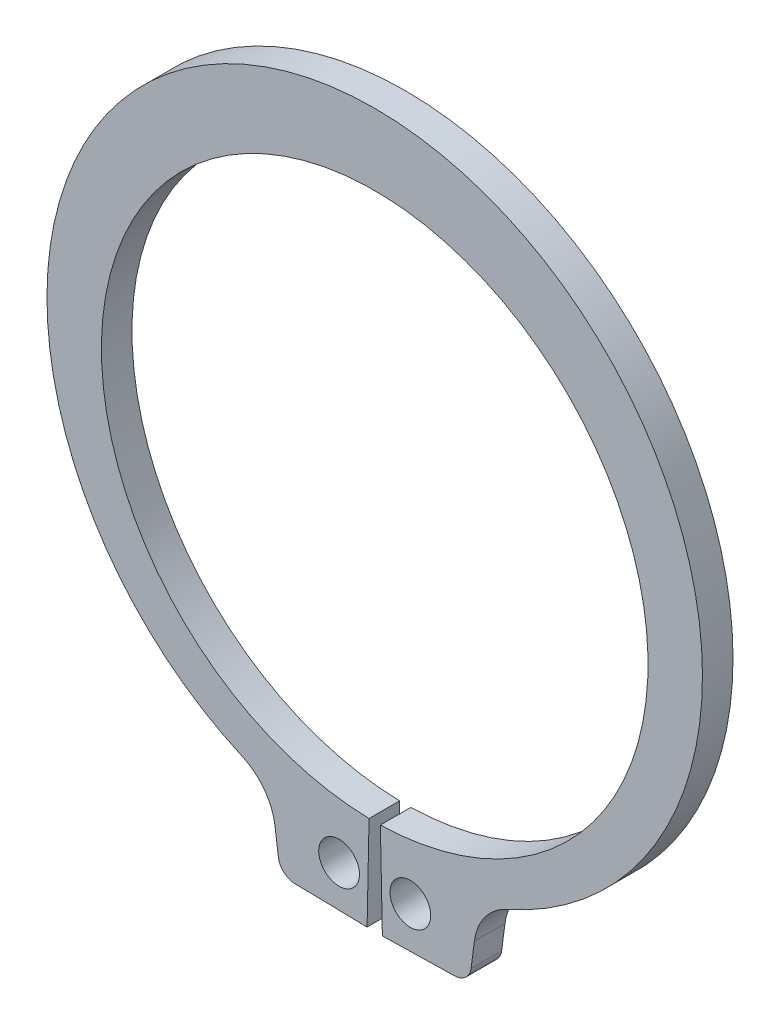
from build123d import *

# Parameters (mm, degrees)
BODYSKE_R  = 0.6
BODY_DEPTH = 0.9


with BuildPart() as part:
    # BodySke → Body (new body)
    with BuildSketch(Plane.XY):
        with BuildLine():
            Line((0.166935484, -8.048268916), (0.225, -10.8476668))
            Line((0.225, -10.8476668), (2.353032971, -10.803527592))
            ThreePointArc((2.353032971, -10.803527592), (2.676217488, -10.676116355), (2.838386738, -10.368898209))
            Line((2.838386738, -10.368898209), (2.936405186, -9.624374178))
            ThreePointArc((2.936405186, -9.624374178), (3.251364406, -8.851047556), (3.904664808, -8.331016828))
            ThreePointArc((3.904664808, -8.331016828), (0, 10.15), (-3.904664808, -8.331016828))
            ThreePointArc((-3.904664808, -8.331016828), (-3.251364406, -8.851047556), (-2.936405186, -9.624374178))
            Line((-2.936405186, -9.624374178), (-2.838386738, -10.368898209))
            ThreePointArc((-2.838386738, -10.368898209), (-2.676217488, -10.676116355), (-2.353032971, -10.803527592))
            Line((-2.353032971, -10.803527592), (-0.225, -10.8476668))
            Line((-0.225, -10.8476668), (-0.166935484, -8.048268916))
            ThreePointArc((-0.166935484, -8.048268916), (0, 8.05), (0.166935484, -8.048268916))
        make_face()
        with Locations((1.05, -9.61785449)):
            Circle(BODYSKE_R, mode=Mode.SUBTRACT)
        with Locations((-1.05, -9.61785449)):
            Circle(BODYSKE_R, mode=Mode.SUBTRACT)
    extrude(amount=-BODY_DEPTH)


solid = part.part
